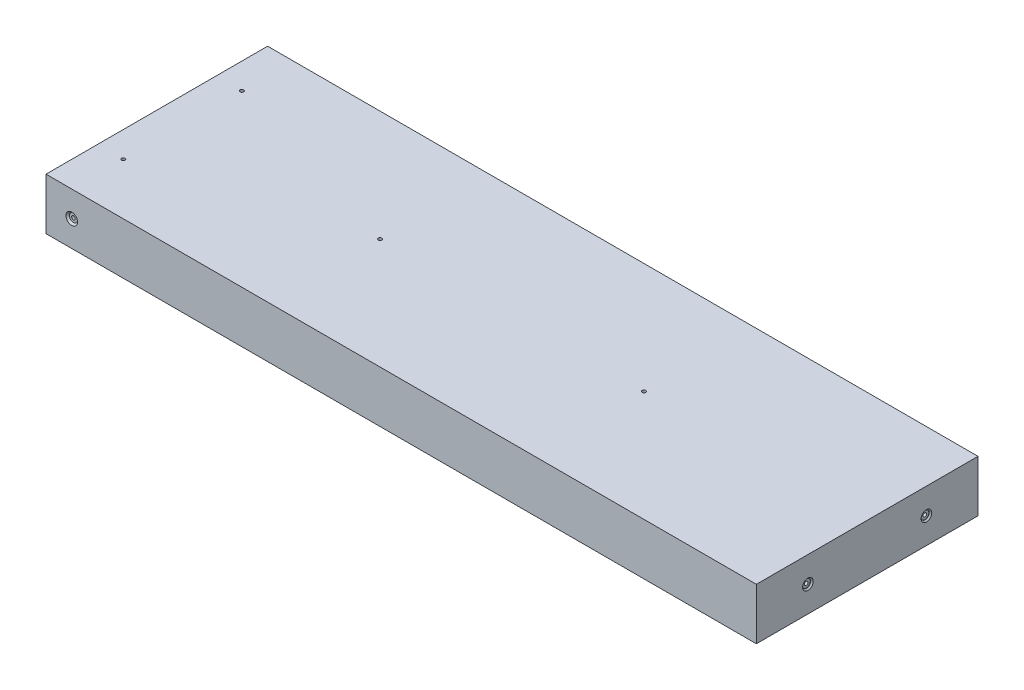
from build123d import *

# Parameters (mm, degrees)
SKETCH1_W                                   = 350
SKETCH1_H                                   = 109.2
BOSS_EXTRUDE1_DEPTH                         = 25.4
CBORE_FOR_0_BINDING_HEAD_MACHINE_SC_2_COUNT = 2
CBORE_FOR_0_BINDING_HEAD_MACHINE_SC_2_PITCH = 58.4
CBORE_FOR_0_BINDING_HEAD_MACHINE_SC_3_COUNT = 2
CBORE_FOR_0_BINDING_HEAD_MACHINE_SC_3_PITCH = 130
CBORE_FOR_0_BINDING_HEAD_MACHINE_SC_4_COUNT = 2
CBORE_FOR_0_BINDING_HEAD_MACHINE_SC_4_PITCH = 58.4


with BuildPart() as part:
    # Sketch1 → Boss-Extrude1 (new body)
    with BuildSketch(Plane(origin=(0, 0, 0), x_dir=(1, 0, 0), z_dir=(0, 1, 0))):
        Rectangle(SKETCH1_W, SKETCH1_H)
    extrude(amount=BOSS_EXTRUDE1_DEPTH)

    # Sketch3 → CBORE for #0 Binding Head Machine Screw1 (revolve, cut)
    with BuildSketch(Plane(origin=(-162.3, 12.7, 54.6), x_dir=(0, -1, 0), z_dir=(1, 0, 0))):
        Polygon((0, 0), (0, 30.53416509), (0.889, 30), (0.889, 0.8128), (1.98501, 0.8128), (1.98501, 0.87249), (2.8575, 0), align=None)
    cbore_for_0_binding_head_machine_screw1 = revolve(axis=Axis((-162.3, 12.7, 60.95), (0, 0, -1)), mode=Mode.SUBTRACT)

    # Mirror1: CBORE for #0 Binding Head Machine Screw1 across plane
    add(cbore_for_0_binding_head_machine_screw1.mirror(Plane.XY), mode=Mode.SUBTRACT)

    # Sketch5 → CBORE for #0 Binding Head Machine Screw2 (revolve, cut)
    with BuildSketch(Plane(origin=(175, 12.7, 29.1995), x_dir=(0, 0, -1), z_dir=(0, 1, 0))):
        Polygon((0, 0), (0, 30.53416509), (0.889, 30), (0.889, 0.8128), (1.98501, 0.8128), (1.98501, 0.635), (2.62001, 0), align=None)
    cbore_for_0_binding_head_machine_screw2 = revolve(axis=Axis((181.35, 12.7, 29.1995), (-1, 0, 0)), mode=Mode.SUBTRACT)

    # CBORE for _0 Binding Head Machine Sc 2: CBORE for #0 Binding Head Machine Screw2 ×2
    with Locations(*[(0, 0, -i * CBORE_FOR_0_BINDING_HEAD_MACHINE_SC_2_PITCH) for i in range(1, CBORE_FOR_0_BINDING_HEAD_MACHINE_SC_2_COUNT)]):
        add(cbore_for_0_binding_head_machine_screw2, mode=Mode.SUBTRACT)

    # Sketch9 → CBORE for #0 Binding Head Machine Screw4 (revolve, cut)
    with BuildSketch(Plane(origin=(-65, 0, 0), x_dir=(0, 0, -1), z_dir=(1, 0, 0))):
        Polygon((0, 0), (0, 30.53416509), (0.889, 30), (0.889, 0.8128), (1.98501, 0.8128), (1.98501, 0.87249), (2.8575, 0), align=None)
    cbore_for_0_binding_head_machine_screw4 = revolve(axis=Axis((-65, -6.35, 0), (0, 1, 0)), mode=Mode.SUBTRACT)

    # CBORE for _0 Binding Head Machine Sc 3: CBORE for #0 Binding Head Machine Screw4 ×2
    with Locations(*[(i * CBORE_FOR_0_BINDING_HEAD_MACHINE_SC_3_PITCH, 0, 0) for i in range(1, CBORE_FOR_0_BINDING_HEAD_MACHINE_SC_3_COUNT)]):
        add(cbore_for_0_binding_head_machine_screw4, mode=Mode.SUBTRACT)

    # Sketch13 → CBORE for #0 Binding Head Machine Screw6 (revolve, cut)
    with BuildSketch(Plane(origin=(-162.3, 0, -29.2), x_dir=(0, 0, -1), z_dir=(1, 0, 0))):
        Polygon((0, 0), (0, 25.4), (0.889, 25.4), (0.889, 0.8128), (1.98501, 0.8128), (1.98501, 0.87249), (2.8575, 0), align=None)
    cbore_for_0_binding_head_machine_screw6 = revolve(axis=Axis((-162.3, -6.35, -29.2), (0, 1, 0)), mode=Mode.SUBTRACT)

    # CBORE for _0 Binding Head Machine Sc 4: CBORE for #0 Binding Head Machine Screw6 ×2
    with Locations(*[(0, 0, i * CBORE_FOR_0_BINDING_HEAD_MACHINE_SC_4_PITCH) for i in range(1, CBORE_FOR_0_BINDING_HEAD_MACHINE_SC_4_COUNT)]):
        add(cbore_for_0_binding_head_machine_screw6, mode=Mode.SUBTRACT)


solid = part.part
